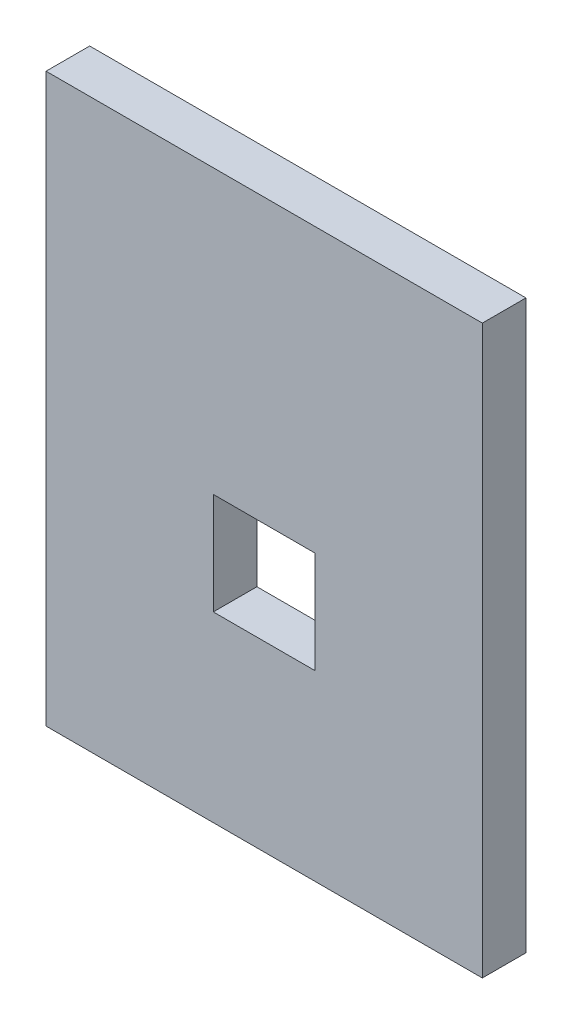
from build123d import *

# Parameters (mm, degrees)
SKETCH2_W           = 190.5
SKETCH2_H           = 247.65
SKETCH2_W_2         = 44.45
SKETCH2_H_2         = 44.45
BOSS_EXTRUDE1_DEPTH = 19.05


with BuildPart() as part:
    # Sketch2 → Boss-Extrude1 (new body)
    with BuildSketch(Plane.XY):
        Rectangle(SKETCH2_W, SKETCH2_H)
        with Locations((0, -21.9075)):
            Rectangle(SKETCH2_W_2, SKETCH2_H_2, mode=Mode.SUBTRACT)
    extrude(amount=BOSS_EXTRUDE1_DEPTH)


solid = part.part
